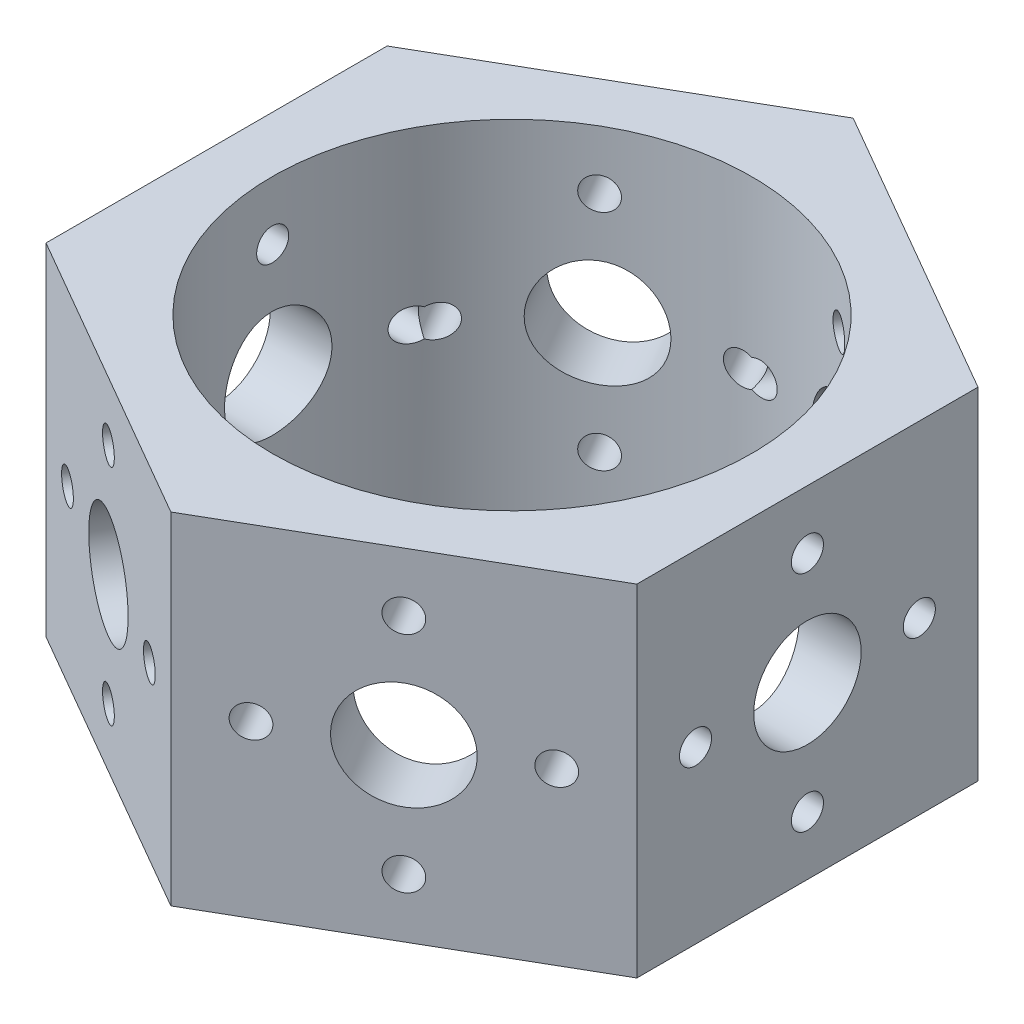
from build123d import *

# Parameters (mm, degrees)
SKETCH1_R               = 17.8562
EXTRUDE1_DEPTH          = 25.4
SKETCH2_R               = 4.0005
SKETCH2_R_2             = 1.1938
CUT_EXTRUDE1_DEPTH      = 25.4
CUT_EXTRUDE1_DEPTH_BACK = 25.4
SKETCH3_R               = 4.0005
SKETCH3_R_2             = 1.1938
CUT_EXTRUDE2_DEPTH      = 25.4
CUT_EXTRUDE2_DEPTH_BACK = 25.4
SKETCH4_R               = 4.0005
SKETCH4_R_2             = 1.1938
CUT_EXTRUDE3_DEPTH      = 25.4
CUT_EXTRUDE3_DEPTH_BACK = 25.4


with BuildPart() as part:
    # Sketch1 → Extrude1 (new body)
    with BuildSketch(Plane(origin=(0, 0, 0), x_dir=(1, 0, 0), z_dir=(0, 1, 0))):
        Polygon((-21.9964, 12.7), (-21.996722628, -12.699441192), (-0.000322628, -25.399441192), (21.9964, -12.7), (21.996722628, 12.699441192), (0.000322628, 25.399441192), align=None)
        with Locations(Location((0, 0, 0), (0, 0, 270))):  # turned: the seam where the file's is
            Circle(SKETCH1_R, mode=Mode.SUBTRACT)
    extrude(amount=EXTRUDE1_DEPTH)

    # Sketch2 → Cut-Extrude1 (cut, two sides)
    with BuildSketch(Plane(origin=(0, 0, 0), x_dir=(0, 0, -1), z_dir=(1, 0, 0))) as cut_extrude1_sk:
        with Locations((-0.000279404, 12.7)):
            Circle(SKETCH2_R)
        with Locations((8.330920596, 12.7)):
            Circle(SKETCH2_R_2)
        with Locations((-0.000279404, 4.3688)):
            Circle(SKETCH2_R_2)
        with Locations((-8.331479404, 12.7)):
            Circle(SKETCH2_R_2)
        with Locations((-0.000279404, 21.0312)):
            Circle(SKETCH2_R_2)
    extrude(amount=CUT_EXTRUDE1_DEPTH, mode=Mode.SUBTRACT)
    extrude(cut_extrude1_sk.sketch, amount=-CUT_EXTRUDE1_DEPTH_BACK, mode=Mode.SUBTRACT)

    # Sketch3 → Cut-Extrude2 (cut, two sides)
    with BuildSketch(Plane(origin=(0, 0, 0), x_dir=(0.866019053, 0, 0.500011), z_dir=(-0.500011, 0, 0.866019053))) as cut_extrude2_sk:
        with Locations((0, 12.7)):
            Circle(SKETCH3_R)
        with Locations((8.3312, 12.7)):
            Circle(SKETCH3_R_2)
        with Locations((0, 4.3688)):
            Circle(SKETCH3_R_2)
        with Locations(Location((-8.3312, 12.7, 0), (0, 0, 119.986803847))):  # turned: the seam where the file's is
            Circle(SKETCH3_R_2)
        with Locations((0, 21.0312)):
            Circle(SKETCH3_R_2)
    extrude(amount=CUT_EXTRUDE2_DEPTH, mode=Mode.SUBTRACT)
    extrude(cut_extrude2_sk.sketch, amount=-CUT_EXTRUDE2_DEPTH_BACK, mode=Mode.SUBTRACT)

    # Sketch4 → Cut-Extrude3 (cut, two sides)
    with BuildSketch(Plane(origin=(0, 0, 0), x_dir=(-0.866031755, 0, 0.499989), z_dir=(-0.499989, 0, -0.866031755))) as cut_extrude3_sk:
        with Locations((0, 12.7)):
            Circle(SKETCH4_R)
        with Locations((8.3312, 12.7)):
            Circle(SKETCH4_R_2)
        with Locations((0, 4.3688)):
            Circle(SKETCH4_R_2)
        with Locations(Location((-8.3312, 12.7, 0), (0, 0, 240))):  # turned: the seam where the file's is
            Circle(SKETCH4_R_2)
        with Locations((0, 21.0312)):
            Circle(SKETCH4_R_2)
    extrude(amount=CUT_EXTRUDE3_DEPTH, mode=Mode.SUBTRACT)
    extrude(cut_extrude3_sk.sketch, amount=-CUT_EXTRUDE3_DEPTH_BACK, mode=Mode.SUBTRACT)


solid = part.part
